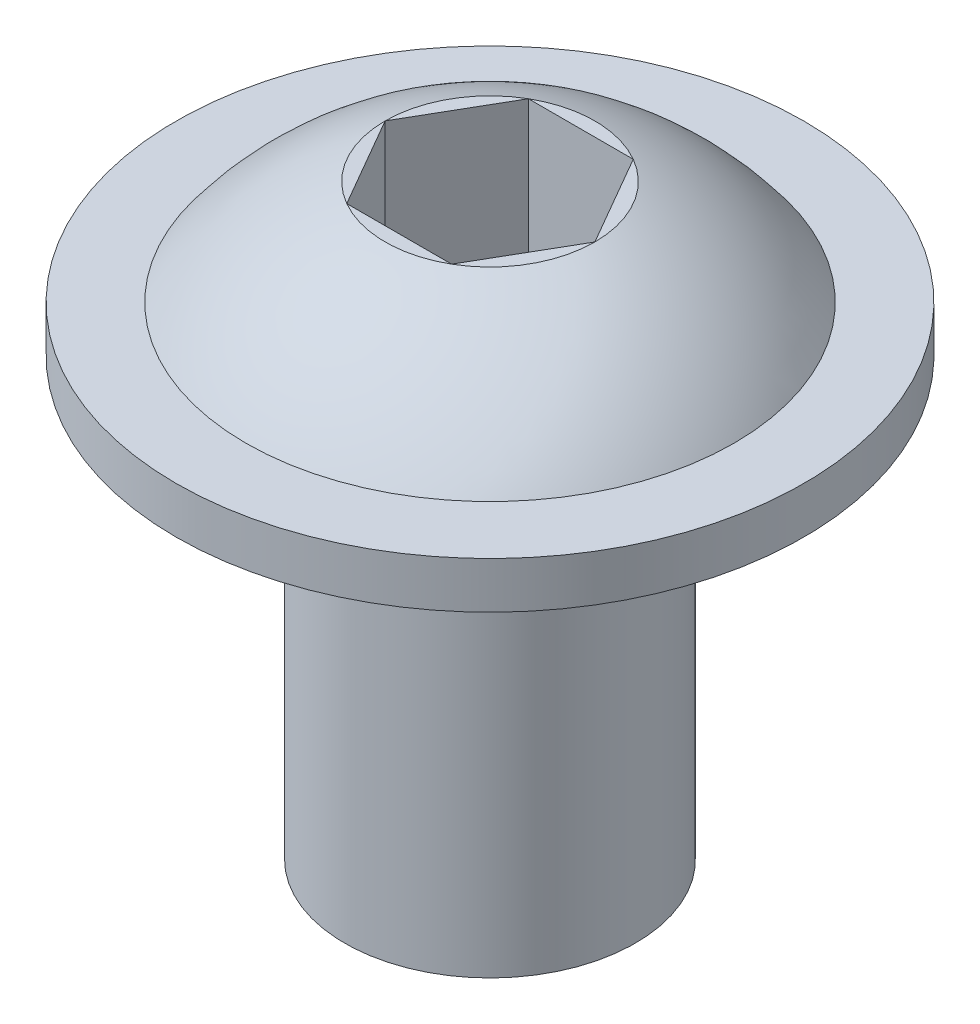
from build123d import *

# Parameters (mm, degrees)
HEX_CUT_DEPTH = 3.175


with BuildPart() as part:
    # Sketch1 → Screw revolve (revolve)
    with BuildSketch(Plane.XY):
        with BuildLine():
            Line((0, 0), (3.175, 0))
            Line((3.175, 0), (3.175, 9.525))
            Line((3.175, 9.525), (6.858, 9.525))
            Line((6.858, 9.525), (6.858, 10.541))
            Line((6.858, 10.541), (5.334, 10.541))
            ThreePointArc((5.334, 10.541), (3.980323293, 11.907132143), (2.291358881, 12.827))
            Line((2.291358881, 12.827), (0, 12.827))
            Line((0, 12.827), (0, 0))
        make_face()
    revolve(axis=Axis((0, 0, 0), (0, 1, 0)))

    # Sketch2 → Hex Cut (cut)
    with BuildSketch(Plane(origin=(0, 12.827, 0), x_dir=(-1, 0, 0), z_dir=(0, 1, 0))):
        Polygon((-2.291358881, 0), (-1.14567944, -1.984375), (1.14567944, -1.984375), (2.291358881, 0), (1.14567944, 1.984375), (-1.14567944, 1.984375), align=None)
    extrude(amount=-HEX_CUT_DEPTH, mode=Mode.SUBTRACT)


solid = part.part
